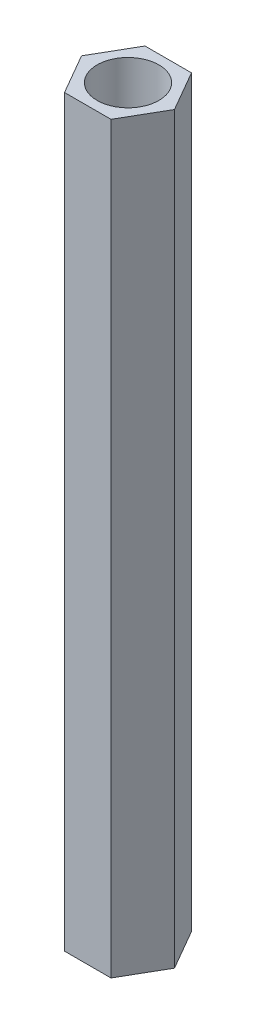
from build123d import *

# Parameters (mm, degrees)
BOSS_EXTRUDE1_DEPTH = 40
SKETCH2_R           = 1.660385814
CUT_EXTRUDE1_DEPTH  = 41


with BuildPart() as part:
    # Sketch1 → Boss-Extrude1 (new body)
    with BuildSketch(Plane(origin=(0, 0, 0), x_dir=(1, 0, 0), z_dir=(0, 1, 0))):
        Polygon((2.5, 0), (1.25, 2.165063509), (-1.25, 2.165063509), (-2.5, 0), (-1.25, -2.165063509), (1.25, -2.165063509), align=None)
    extrude(amount=BOSS_EXTRUDE1_DEPTH)

    # Sketch2 → Cut-Extrude1 (cut, through all)
    with BuildSketch(Plane(origin=(0, 40, 0), x_dir=(1, 0, 0), z_dir=(0, 1, 0))):
        Circle(SKETCH2_R)
    extrude(amount=-CUT_EXTRUDE1_DEPTH, mode=Mode.SUBTRACT)


solid = part.part
